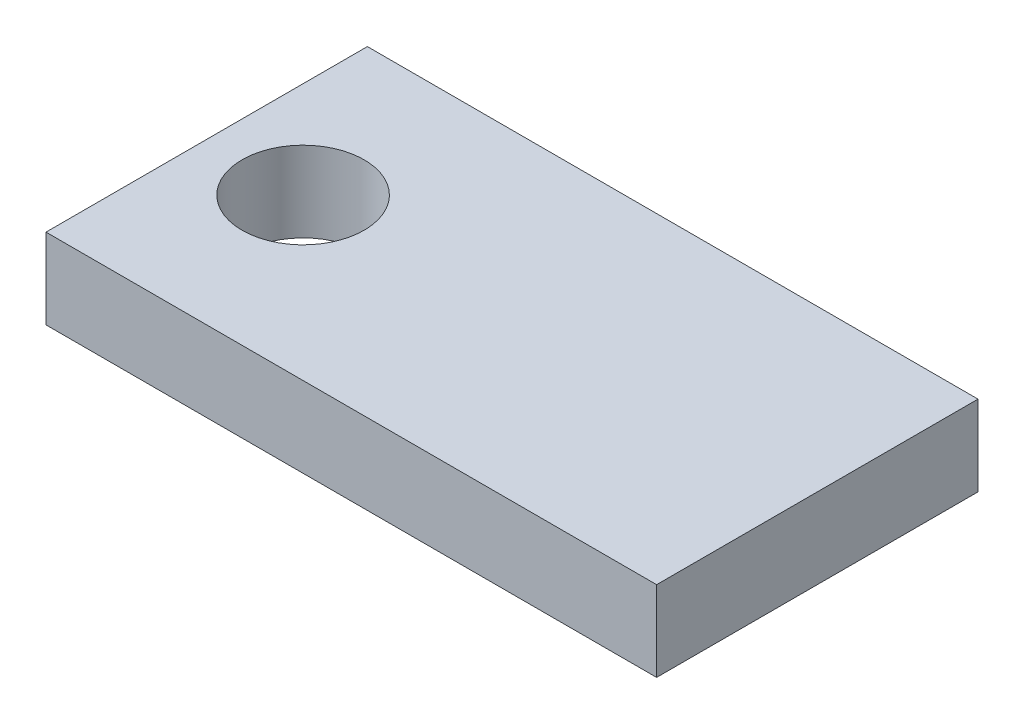
from build123d import *

# Parameters (mm, degrees)
SKETCH1_W           = 48.26
SKETCH1_H           = 25.4
BOSS_EXTRUDE1_DEPTH = 6.35
SKETCH2_R           = 4.826
CUT_EXTRUDE1_DEPTH  = 8.89


with BuildPart() as part:
    # Sketch1 → Boss-Extrude1 (new body)
    with BuildSketch(Plane(origin=(0, 0, 0), x_dir=(1, 0, 0), z_dir=(0, 1, 0))):
        Rectangle(SKETCH1_W, SKETCH1_H)
    extrude(amount=BOSS_EXTRUDE1_DEPTH)

    # Sketch2 → Cut-Extrude1 (cut)
    with BuildSketch(Plane(origin=(0, 6.35, 0), x_dir=(1, 0, 0), z_dir=(0, 1, 0))):
        with Locations((-16.51, 0)):
            Circle(SKETCH2_R)
    extrude(amount=-CUT_EXTRUDE1_DEPTH, mode=Mode.SUBTRACT)


solid = part.part
